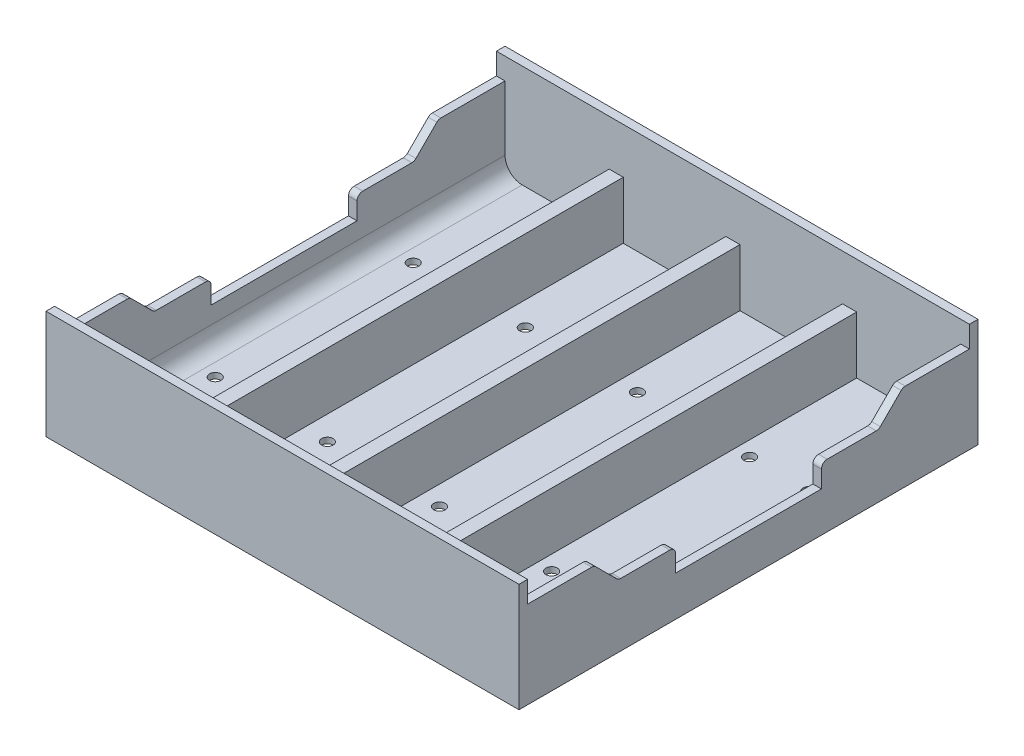
from build123d import *

# Parameters (mm, degrees)
SKETCH1_W             = 82.68
SKETCH1_H             = 80.24
BOSS_EXTRUDE1_DEPTH   = 19
SKETCH2_W             = 79.68
SKETCH2_H             = 77.24
CUT_EXTRUDE1_DEPTH    = 18
CUT_EXTRUDE2_DEPTH    = 117.770886783
FILLET1_R             = 3
F_2_0MM_DOWEL_HOLE1_D = 2
RIB1_REACH            = 117.739
SKETCH5_WALLS_W       = 2.46
SKETCH5_WALLS_H       = 310.717342304


with BuildPart() as part:
    # Sketch1 → Boss-Extrude1 (new body)
    with BuildSketch(Plane(origin=(0, 0, 0), x_dir=(1, 0, 0), z_dir=(0, 1, 0))):
        with Locations((41.34, 40.12)):
            Rectangle(SKETCH1_W, SKETCH1_H)
    extrude(amount=BOSS_EXTRUDE1_DEPTH)

    # Sketch2 → Cut-Extrude1 (cut)
    with BuildSketch(Plane(origin=(0, 19, 0), x_dir=(1, 0, 0), z_dir=(0, 1, 0))):
        with Locations((41.34, 40.12)):
            Rectangle(SKETCH2_W, SKETCH2_H)
    extrude(amount=-CUT_EXTRUDE1_DEPTH, mode=Mode.SUBTRACT)

    # Sketch3 → Cut-Extrude2 (cut, through all)
    with BuildSketch(Plane(origin=(82.68, 0, 0), x_dir=(0, 0, -1), z_dir=(1, 0, 0))):
        with BuildLine():
            Line((27.37, 7), (52.87, 7))
            Line((52.87, 7), (52.87, 10))
            ThreePointArc((52.87, 10), (53.162893219, 10.707106781), (53.87, 11))
            Line((53.87, 11), (62.455786438, 11))
            ThreePointArc((62.455786438, 11), (62.83846987, 11.076120467), (63.162893219, 11.292893219))
            Line((63.162893219, 11.292893219), (66.819747468, 14.949747468))
            ThreePointArc((66.819747468, 14.949747468), (67.144170817, 15.16652022), (67.526854249, 15.242640687))
            Line((67.526854249, 15.242640687), (78.74, 15.242640687))
            Line((78.74, 15.242640687), (78.74, 19))
            Line((78.74, 19), (1.5, 19))
            Line((1.5, 19), (1.5, 15.242640687))
            Line((1.5, 15.242640687), (12.713145751, 15.242640687))
            ThreePointArc((12.713145751, 15.242640687), (13.095829183, 15.16652022), (13.420252532, 14.949747468))
            Line((13.420252532, 14.949747468), (17.077106781, 11.292893219))
            ThreePointArc((17.077106781, 11.292893219), (17.40153013, 11.076120467), (17.784213562, 11))
            Line((17.784213562, 11), (26.37, 11))
            ThreePointArc((26.37, 11), (27.077106781, 10.707106781), (27.37, 10))
            Line((27.37, 10), (27.37, 7))
        make_face()
    extrude(amount=-CUT_EXTRUDE2_DEPTH, mode=Mode.SUBTRACT)

    # Fillet1
    fillet1_edges = [part.edges().sort_by_distance(p)[0] for p in [
        (81.18, 1, -40.12),
        (1.5, 1, -40.12),
    ]]
    fillet(fillet1_edges, radius=FILLET1_R)

    # Ø2.0mm Dowel Hole1 (through all)
    with Locations(Plane(origin=(0, 0, 0), x_dir=(-1, 0, 0), z_dir=(0, -1, 0))):
        with Locations((-6.765, 57.42), (-17.115, 57.42), (-26.365, 57.42), (-36.715, 57.42), (-45.965, 57.42), (-56.315, 57.42), (-65.565, 57.42), (-75.915, 57.42), (-75.915, 22.82), (-65.565, 22.82), (-56.315, 22.82), (-45.965, 22.82), (-36.715, 22.82), (-26.365, 22.82), (-17.115, 22.82), (-6.765, 22.82)):
            Hole(F_2_0MM_DOWEL_HOLE1_D / 2)

    # Sketch5 walls → Rib1 (add, up to next)
    with BuildSketch(Plane(origin=(0, 11, 0), x_dir=(1, 0, 0), z_dir=(0, 1, 0)), mode=Mode.PRIVATE) as rib1_sk1:
        with Locations((20.94, 40.12)):
            Rectangle(SKETCH5_WALLS_W, SKETCH5_WALLS_H)
    rib1_tool1 = extrude(rib1_sk1.sketch, amount=-RIB1_REACH, mode=Mode.PRIVATE) - part.part
    # Sketch5 walls → Rib1 (add, up to next)
    with BuildSketch(Plane(origin=(0, 11, 0), x_dir=(1, 0, 0), z_dir=(0, 1, 0)), mode=Mode.PRIVATE) as rib1_sk2:
        with Locations((41.34, 40.12)):
            Rectangle(SKETCH5_WALLS_W, SKETCH5_WALLS_H)
    rib1_tool2 = extrude(rib1_sk2.sketch, amount=-RIB1_REACH, mode=Mode.PRIVATE) - part.part
    # Sketch5 walls → Rib1 (add, up to next)
    with BuildSketch(Plane(origin=(0, 11, 0), x_dir=(1, 0, 0), z_dir=(0, 1, 0)), mode=Mode.PRIVATE) as rib1_sk3:
        with Locations((61.74, 40.12)):
            Rectangle(SKETCH5_WALLS_W, SKETCH5_WALLS_H)
    rib1_tool3 = extrude(rib1_sk3.sketch, amount=-RIB1_REACH, mode=Mode.PRIVATE) - part.part
    add(rib1_tool1.solids().sort_by_distance((20.94, 11, -40.12))[0])
    add(rib1_tool2.solids().sort_by_distance((41.34, 11, -40.12))[0])
    add(rib1_tool3.solids().sort_by_distance((61.74, 11, -40.12))[0])


solid = part.part
